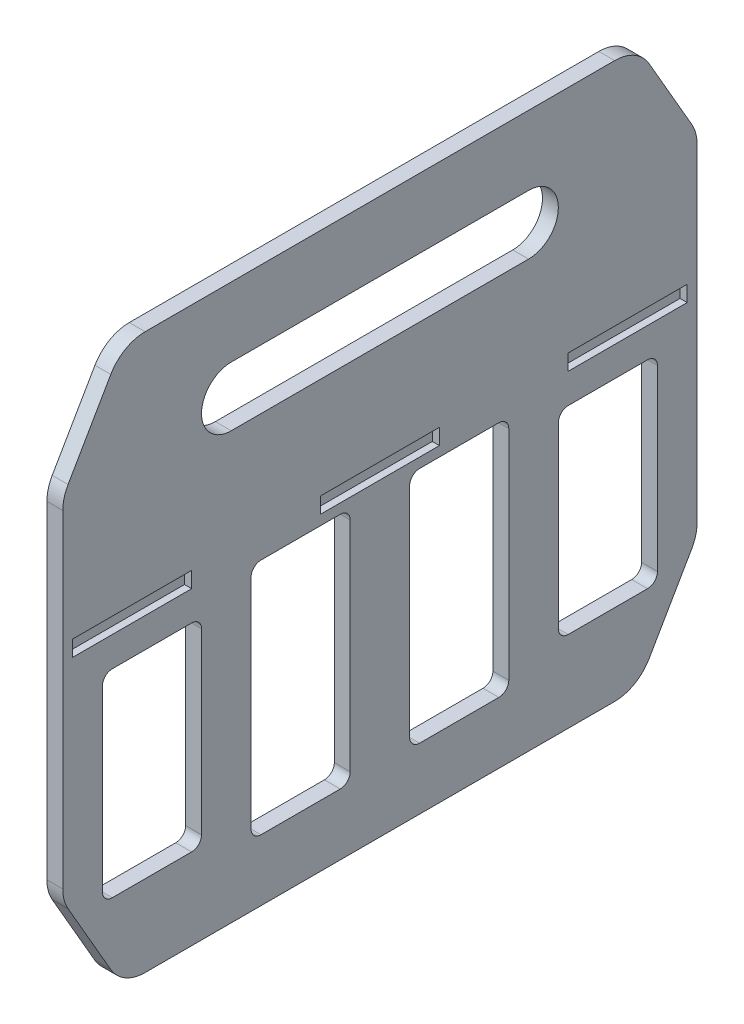
from build123d import *

# Parameters (mm, degrees)
BOSS_EXTRUDE1_DEPTH   = 10.16
SKETCH2_W             = 76.2
SKETCH2_H             = 10.16
CUT_EXTRUDE1_DEPTH    = 4.572
CHAMFER1_SIZE         = 38.1
CHAMFER1_SIZE2        = 65.991135768
CHAMFER1_PART_2_SIZE  = 38.1
CHAMFER1_PART_2_SIZE2 = 65.991135768
FILLET1_R             = 25.4
CUT_EXTRUDE2_DEPTH    = 11.16


with BuildPart() as part:
    # Sketch1 → Boss-Extrude1 (new body)
    with BuildSketch(Plane(origin=(0, 0, 0), x_dir=(0, 0, -1), z_dir=(1, 0, 0))):
        Polygon((-203.2, 0), (-203.2, 254), (-203.2, 279.4), (203.2, 279.4), (203.2, 254), (203.2, 0), (203.2, -76.2), (-203.2, -76.2), align=None)
        with BuildLine():
            Line((-95.25, 234.95), (95.25, 234.95))
            ThreePointArc((95.25, 234.95), (114.3, 215.9), (95.25, 196.85))
            Line((95.25, 196.85), (-95.25, 196.85))
            ThreePointArc((-95.25, 196.85), (-114.3, 215.9), (-95.25, 234.95))
        make_face(mode=Mode.SUBTRACT)
    extrude(amount=-BOSS_EXTRUDE1_DEPTH)

    # Sketch2 → Cut-Extrude1 (cut)
    with BuildSketch(Plane(origin=(0, 0, 0), x_dir=(0, 0, -1), z_dir=(1, 0, 0))):
        with Locations((-158.75, 127)):
            Rectangle(SKETCH2_W, SKETCH2_H)
        with Locations((0, 127)):
            Rectangle(SKETCH2_W, SKETCH2_H)
        with Locations((158.75, 127)):
            Rectangle(SKETCH2_W, SKETCH2_H)
    extrude(amount=-CUT_EXTRUDE1_DEPTH, mode=Mode.SUBTRACT)

    # Chamfer1
    chamfer1_edges = [part.edges().sort_by_distance(p)[0] for p in [
        (-5.08, 279.4, 203.2),
        (-5.08, 279.4, -203.2),
    ]]
    chamfer1_side = [part.faces().sort_by_distance(p)[0] for p in [
        (-5.08, 279.4, 0),
    ]]
    chamfer(chamfer1_edges, length=CHAMFER1_SIZE, length2=CHAMFER1_SIZE2, reference=chamfer1_side[0])

    # Chamfer1 part 2
    chamfer1_part_2_edges = [part.edges().sort_by_distance(p)[0] for p in [
        (-5.08, -76.2, -203.2),
        (-5.08, -76.2, 203.2),
    ]]
    chamfer1_part_2_side = [part.faces().sort_by_distance(p)[0] for p in [
        (-5.08, -76.2, 0),
    ]]
    chamfer(chamfer1_part_2_edges, length=CHAMFER1_PART_2_SIZE, length2=CHAMFER1_PART_2_SIZE2, reference=chamfer1_part_2_side[0])

    # Fillet1
    fillet1_edges = [part.edges().sort_by_distance(p)[0] for p in [
        (-5.08, -76.2, 165.1),
        (-5.08, -76.2, -165.1),
        (-5.08, 213.408864232, -203.2),
        (-5.08, -10.208864232, -203.2),
        (-5.08, 213.408864232, 203.2),
        (-5.08, -10.208864232, 203.2),
        (-5.08, 279.4, -165.1),
        (-5.08, 279.4, 165.1),
    ]]
    fillet(fillet1_edges, radius=FILLET1_R)

    # Sketch11 → Cut-Extrude2 (cut, through all)
    with BuildSketch(Plane(origin=(0, 0, 0), x_dir=(0, 0, -1), z_dir=(1, 0, 0))):
        with BuildLine():
            Line((-171.45, 102.87), (-120.65, 102.87))
            ThreePointArc((-120.65, 102.87), (-116.159871939, 101.010128061), (-114.3, 96.52))
            Line((-114.3, 96.52), (-114.3, -17.78))
            ThreePointArc((-114.3, -17.78), (-116.159871939, -22.270128061), (-120.65, -24.13))
            Line((-120.65, -24.13), (-171.45, -24.13))
            ThreePointArc((-171.45, -24.13), (-175.940128061, -22.270128061), (-177.8, -17.78))
            Line((-177.8, -17.78), (-177.8, 96.52))
            ThreePointArc((-177.8, 96.52), (-175.940128061, 101.010128061), (-171.45, 102.87))
        make_face()
        with BuildLine():
            Line((-76.2, 115.57), (-25.4, 115.57))
            ThreePointArc((-25.4, 115.57), (-20.909871939, 113.710128061), (-19.05, 109.22))
            Line((-19.05, 109.22), (-19.05, -30.48))
            ThreePointArc((-19.05, -30.48), (-20.909871939, -34.970128061), (-25.4, -36.83))
            Line((-25.4, -36.83), (-76.2, -36.83))
            ThreePointArc((-76.2, -36.83), (-80.690128061, -34.970128061), (-82.55, -30.48))
            Line((-82.55, -30.48), (-82.55, 109.22))
            ThreePointArc((-82.55, 109.22), (-80.690128061, 113.710128061), (-76.2, 115.57))
        make_face()
        with BuildLine():
            Line((19.05, 109.22), (19.05, -30.48))
            ThreePointArc((19.05, -30.48), (20.909871939, -34.970128061), (25.4, -36.83))
            Line((25.4, -36.83), (76.2, -36.83))
            ThreePointArc((76.2, -36.83), (80.690128061, -34.970128061), (82.55, -30.48))
            Line((82.55, -30.48), (82.55, 109.22))
            ThreePointArc((82.55, 109.22), (80.690128061, 113.710128061), (76.2, 115.57))
            Line((76.2, 115.57), (25.4, 115.57))
            ThreePointArc((25.4, 115.57), (20.909871939, 113.710128061), (19.05, 109.22))
        make_face()
        with BuildLine():
            Line((114.3, 96.52), (114.3, -17.78))
            ThreePointArc((114.3, -17.78), (116.159871939, -22.270128061), (120.65, -24.13))
            Line((120.65, -24.13), (171.45, -24.13))
            ThreePointArc((171.45, -24.13), (175.940128061, -22.270128061), (177.8, -17.78))
            Line((177.8, -17.78), (177.8, 96.52))
            ThreePointArc((177.8, 96.52), (175.940128061, 101.010128061), (171.45, 102.87))
            Line((171.45, 102.87), (120.65, 102.87))
            ThreePointArc((120.65, 102.87), (116.159871939, 101.010128061), (114.3, 96.52))
        make_face()
    extrude(amount=-CUT_EXTRUDE2_DEPTH, mode=Mode.SUBTRACT)


solid = part.part
